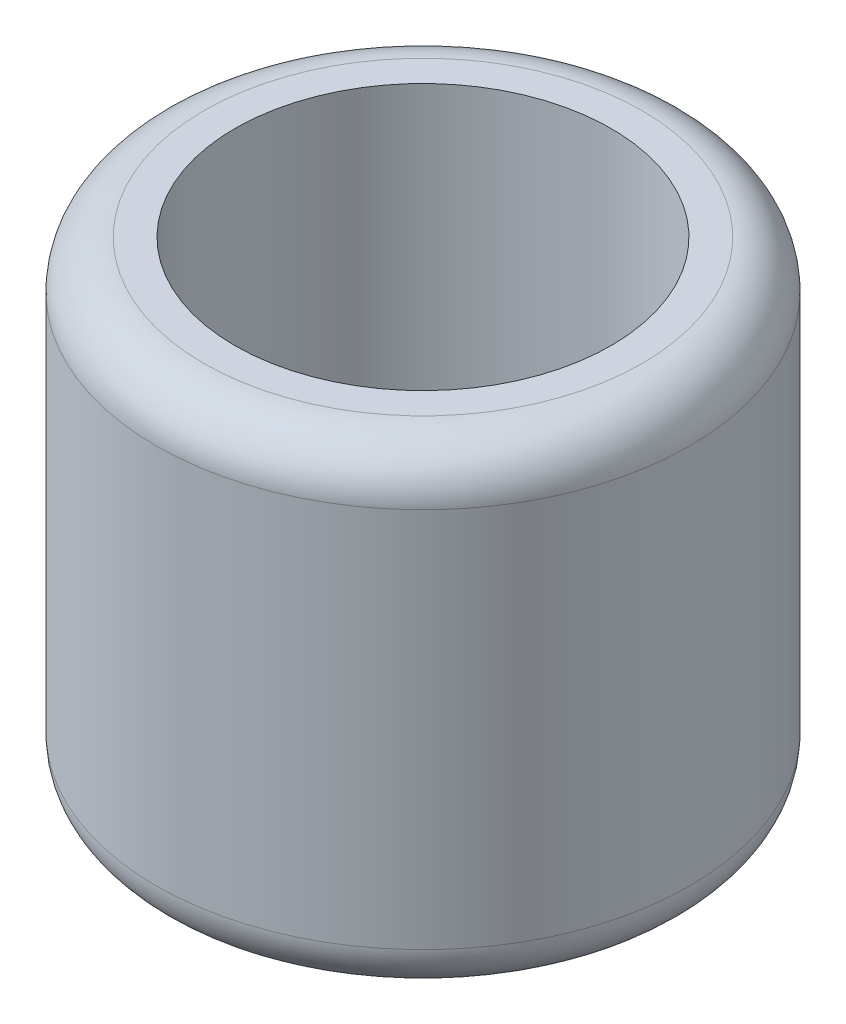
from build123d import *

# Parameters (mm, degrees)
SKETCH1_R           = 5.6
SKETCH1_R_2         = 3.95
BOSS_EXTRUDE1_DEPTH = 10
FILLET1_R           = 1


with BuildPart() as part:
    # Sketch1 → Boss-Extrude1 (new body)
    with BuildSketch(Plane(origin=(0, 0, 0), x_dir=(1, 0, 0), z_dir=(0, 1, 0))):
        Circle(SKETCH1_R)
        Circle(SKETCH1_R_2, mode=Mode.SUBTRACT)
    extrude(amount=BOSS_EXTRUDE1_DEPTH)

    # Fillet1
    fillet1_edges = [part.edges().sort_by_distance(p)[0] for p in [
        (-5.6, 0, 0),
        (-5.6, 10, 0),
    ]]
    fillet(fillet1_edges, radius=FILLET1_R)


solid = part.part
